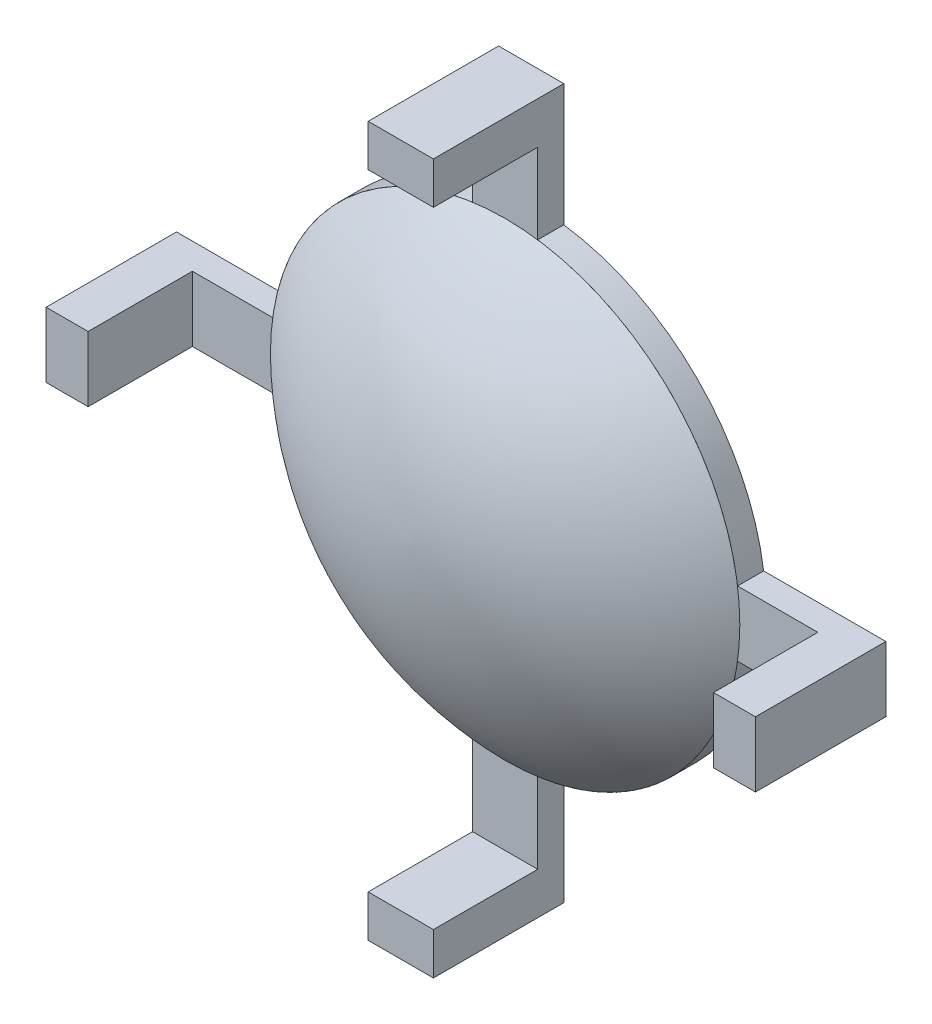
from build123d import *

# Parameters (mm, degrees)
SKETCH1_R           = 9
SKETCH1_W           = 27.2
SKETCH1_H           = 2.5
SKETCH1_W_2         = 2.5
SKETCH1_H_2         = 27.2
BOSS_EXTRUDE1_DEPTH = 1
SKETCH2_W           = 1.609397648
SKETCH2_H           = 2.5
SKETCH2_W_2         = 2.5
SKETCH2_H_2         = 1.609397648
BOSS_EXTRUDE2_DEPTH = 4


with BuildPart() as part:
    # Sketch1 → Boss-Extrude1 (new body)
    with BuildSketch(Plane.XY):
        Circle(SKETCH1_R)
        Rectangle(SKETCH1_W, SKETCH1_H)
        Rectangle(SKETCH1_W_2, SKETCH1_H_2)
    extrude(amount=BOSS_EXTRUDE1_DEPTH)

    # Sketch2 → Boss-Extrude2 (add)
    with BuildSketch(Plane.XY.offset(1)):
        with Locations((-12.795301176, 0)):
            Rectangle(SKETCH2_W, SKETCH2_H)
        with Locations((0, 12.795301176)):
            Rectangle(SKETCH2_W_2, SKETCH2_H_2)
        with Locations((12.795301176, 0)):
            Rectangle(SKETCH2_W, SKETCH2_H)
        with Locations((0, -12.795301176)):
            Rectangle(SKETCH2_W_2, SKETCH2_H_2)
    extrude(amount=BOSS_EXTRUDE2_DEPTH)


with BuildPart() as body_2:
    # Sketch7 → Revolve4 (revolve)
    with BuildSketch(Plane(origin=(0, 0, 0), x_dir=(1, 0, 0), z_dir=(0, 1, 0))):
        with BuildLine():
            Line((-0.000156816, -1), (-9.000156816, -1))
            ThreePointArc((-9.000156816, -1), (-4.843081536, -3.684141213), (-0.000156816, -4.7))
            Line((-0.000156816, -4.7), (-0.000156816, -1))
        make_face()
    revolve(axis=Axis((-0.000156816, 0, 4.7), (0, 0, 1)))


solid = Compound([part.part, body_2.part])
